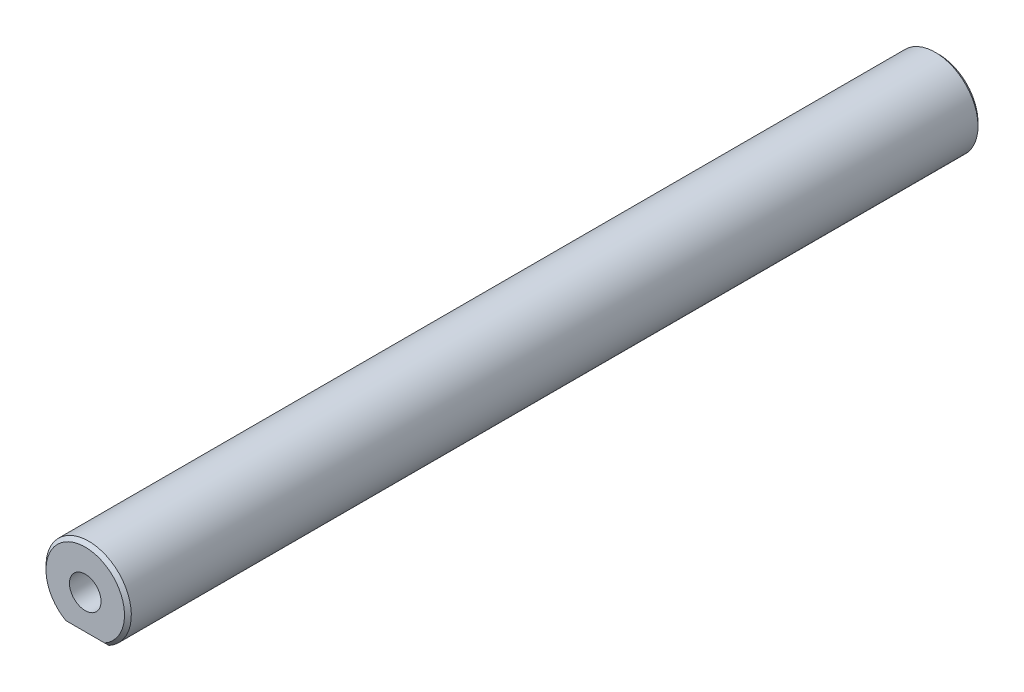
from build123d import *

# Parameters (mm, degrees)
SKETCH1_R           = 5
BOSS_EXTRUDE1_DEPTH = 50
CUT_EXTRUDE1_DEPTH  = 101
CHAMFER1_SIZE       = 0.4


with BuildPart() as part:
    # Sketch1 → Boss-Extrude1 (new body, symmetric)
    with BuildSketch(Plane.XY):
        Circle(SKETCH1_R)
    extrude(amount=BOSS_EXTRUDE1_DEPTH, both=True)

    # Sketch3 → Hole1 (revolve, cut)
    with BuildSketch(Plane(origin=(0, 0, 50), x_dir=(0, -1, 0), z_dir=(1, 0, 0))):
        Polygon((0, 0), (0, 13.85), (1.85, 12), (1.85, 0), align=None)
    hole1 = revolve(axis=Axis((0, 0, 54.244199587), (0, 0, -1)), mode=Mode.SUBTRACT)

    # Mirror7: Hole1 across plane
    add(hole1.mirror(Plane.XY), mode=Mode.SUBTRACT)

    # Sketch4 → Cut-Extrude1 (cut, through all)
    with BuildSketch(Plane.XY.offset(50)):
        with BuildLine():
            Line((-2.374868417, -4.4), (2.374868417, -4.4))
            ThreePointArc((2.374868417, -4.4), (0, -5), (-2.374868417, -4.4))
        make_face()
    extrude(amount=-CUT_EXTRUDE1_DEPTH, mode=Mode.SUBTRACT)

    # Chamfer1
    chamfer1_edges = [part.edges().sort_by_distance(p)[0] for p in [
        (0, 5, -50),
        (0, 5, 50),
        (0, -4.4, -50),
        (0, -4.4, 50),
    ]]
    chamfer(chamfer1_edges, length=CHAMFER1_SIZE)


solid = part.part
